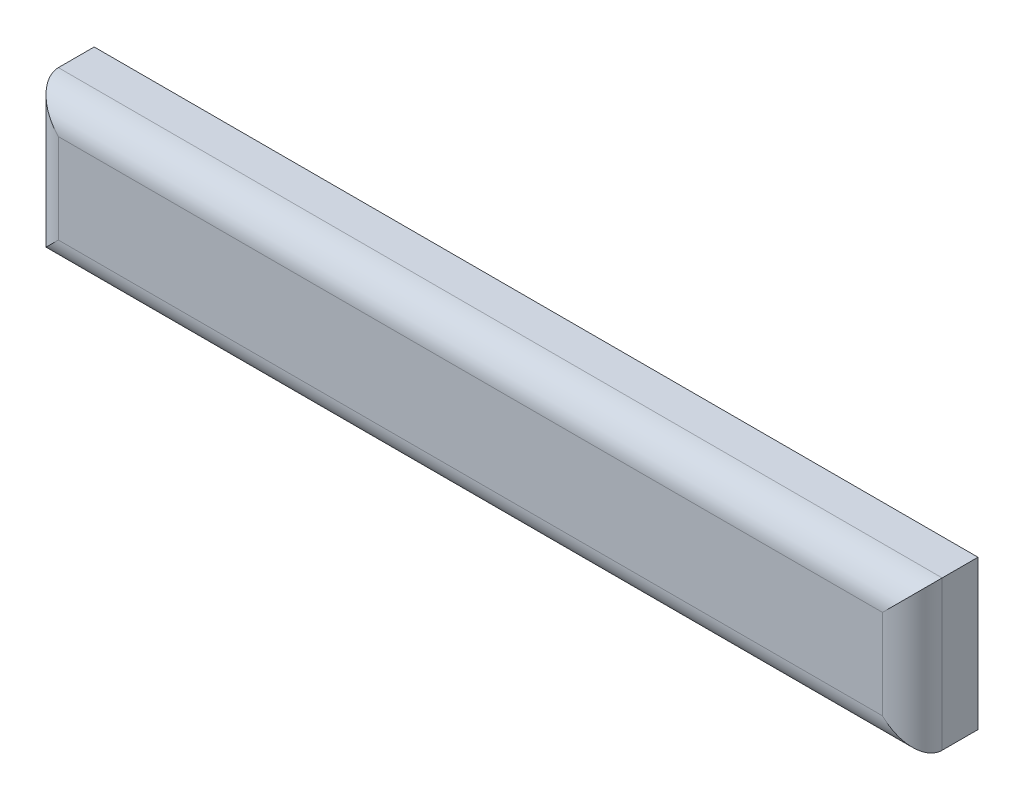
from build123d import *

# Parameters (mm, degrees)
CROQUIS1_W              = 148
CROQUIS1_H              = 25
SALIENTE_EXTRUIR1_DEPTH = 11
REDONDEO1_R             = 5
CROQUIS2_R              = 5.875
CORTAR_EXTRUIR1_DEPTH   = 9
CROQUIS3_R              = 7
CORTAR_EXTRUIR2_DEPTH   = 4.5


with BuildPart() as part:
    # Croquis1 → Saliente-Extruir1 (new body)
    with BuildSketch(Plane.XY):
        with Locations((38.75, -35)):
            Rectangle(CROQUIS1_W, CROQUIS1_H)
    extrude(amount=SALIENTE_EXTRUIR1_DEPTH)

    # Redondeo1
    redondeo1_edges = [part.edges().sort_by_distance(p)[0] for p in [
        (112.75, -35, 11),
        (38.75, -22.5, 11),
        (-35.25, -35, 11),
        (38.75, -47.5, 11),
    ]]
    fillet(redondeo1_edges, radius=REDONDEO1_R)

    # Croquis2 → Cortar-Extruir1 (cut)
    with BuildSketch(Plane(origin=(0, 0, 0), x_dir=(-1, 0, 0), z_dir=(0, 0, -1))):
        with Locations((-73.75, -35)):
            Circle(CROQUIS2_R)
        with Locations(Location((-3.75, -35, 0), (0, 0, 180))):  # turned: the seam where the file's is
            Circle(CROQUIS2_R)
    extrude(amount=-CORTAR_EXTRUIR1_DEPTH, mode=Mode.SUBTRACT)

    # Croquis3 → Cortar-Extruir2 (cut)
    with BuildSketch(Plane(origin=(0, 0, 0), x_dir=(-1, 0, 0), z_dir=(0, 0, -1))):
        with Locations((-73.75, -35)):
            Circle(CROQUIS3_R)
        with Locations(Location((-3.75, -35, 0), (0, 0, 180))):  # turned: the seam where the file's is
            Circle(CROQUIS3_R)
    extrude(amount=-CORTAR_EXTRUIR2_DEPTH, mode=Mode.SUBTRACT)


solid = part.part
